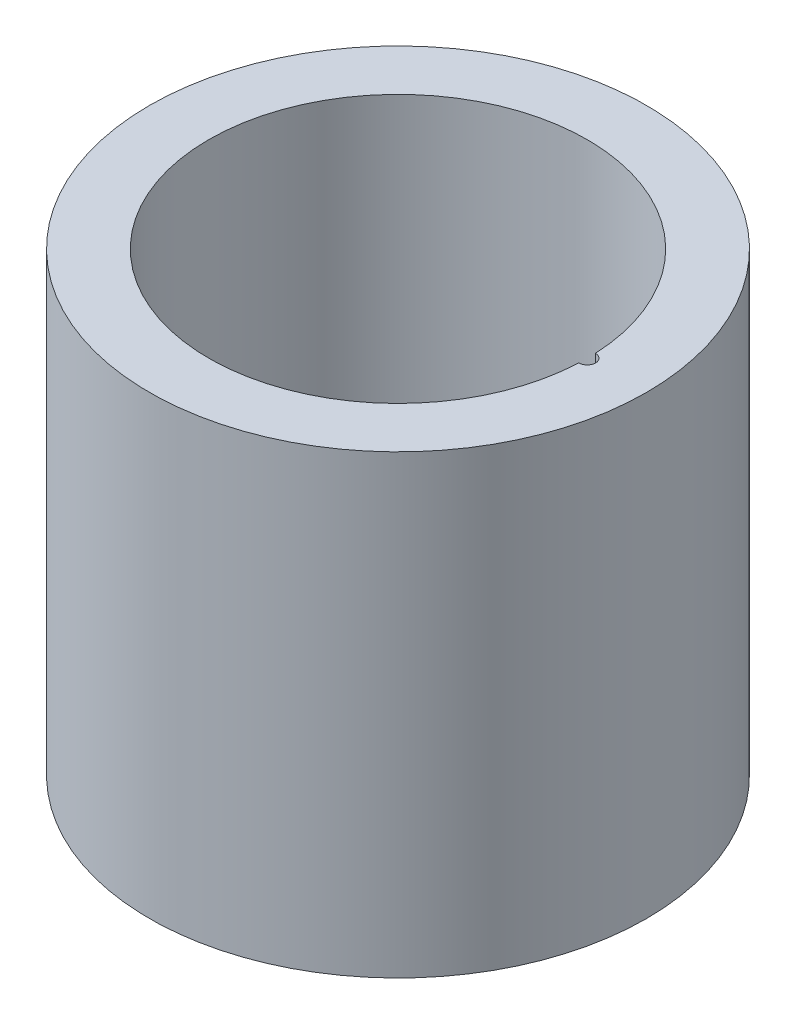
from build123d import *

# Parameters (mm, degrees)
SKETCH6_R          = 1
CUT_EXTRUDE4_DEPTH = 40


with BuildPart() as part:
    # Sketch4 → Revolve2 (revolve)
    with BuildSketch(Plane.XY):
        Polygon((0, 0), (30, 0), (30, 55), (22.847682119, 55), (22.847682119, 15), (23.847682119, 15), (23.847682119, 10), (22.847682119, 10), (22.847682119, 5), (0, 5), align=None)
    revolve(axis=Axis((0, -1100.033698247, 0), (0, 1, 0)))

    # Sketch6 → Cut-Extrude4 (cut)
    with BuildSketch(Plane(origin=(0, 55, 0), x_dir=(1, 0, 0), z_dir=(0, 1, 0))):
        with Locations((22.847682119, 0)):
            Circle(SKETCH6_R)
    extrude(amount=-CUT_EXTRUDE4_DEPTH, mode=Mode.SUBTRACT)


solid = part.part
